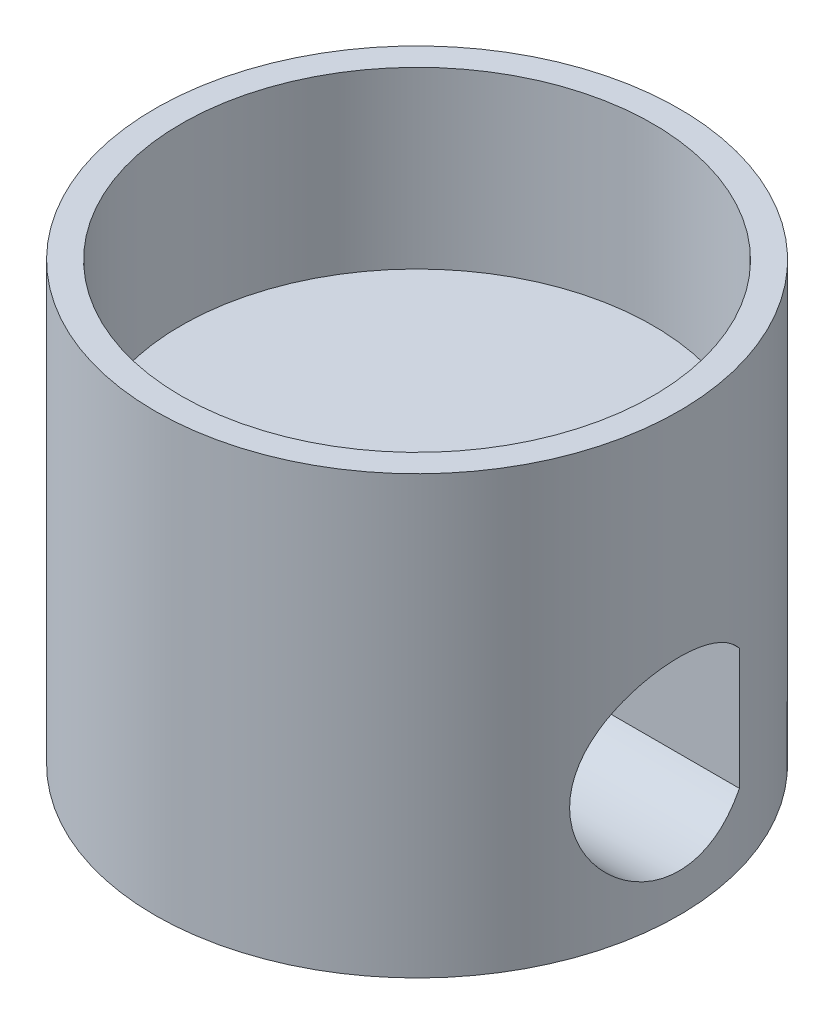
from build123d import *

# Parameters (mm, degrees)
ESBO_O1_R                  = 15
RESSALTO_EXTRUS_O1_DEPTH   = 25
ESBO_O2_R                  = 13.5
CORTE_EXTRUS_O1_DEPTH      = 10
CORTE_EXTRUS_O3_DEPTH      = 16
CORTE_EXTRUS_O3_DEPTH_BACK = 16


with BuildPart() as part:
    # Esboço1 → Ressalto-extrusão1 (new body)
    with BuildSketch(Plane(origin=(0, 0, 0), x_dir=(1, 0, 0), z_dir=(0, 1, 0))):
        Circle(ESBO_O1_R)
    extrude(amount=RESSALTO_EXTRUS_O1_DEPTH)

    # Esboço2 → Corte-extrusão1 (cut)
    with BuildSketch(Plane(origin=(0, 25, 0), x_dir=(1, 0, 0), z_dir=(0, 1, 0))):
        Circle(ESBO_O2_R)
    extrude(amount=-CORTE_EXTRUS_O1_DEPTH, mode=Mode.SUBTRACT)

    # Esboço4 → Corte-extrusão3 (cut, two sides)
    with BuildSketch(Plane(origin=(0, 0, 0), x_dir=(0, 0, -1), z_dir=(1, 0, 0))) as corte_extrus_o3_sk:
        with BuildLine():
            ThreePointArc((4, 10.97706773), (-5.3, 7.5), (4, 4.02293227))
            Line((4, 4.02293227), (4, 10.97706773))
        make_face()
    extrude(amount=CORTE_EXTRUS_O3_DEPTH, mode=Mode.SUBTRACT)
    extrude(corte_extrus_o3_sk.sketch, amount=-CORTE_EXTRUS_O3_DEPTH_BACK, mode=Mode.SUBTRACT)


solid = part.part
